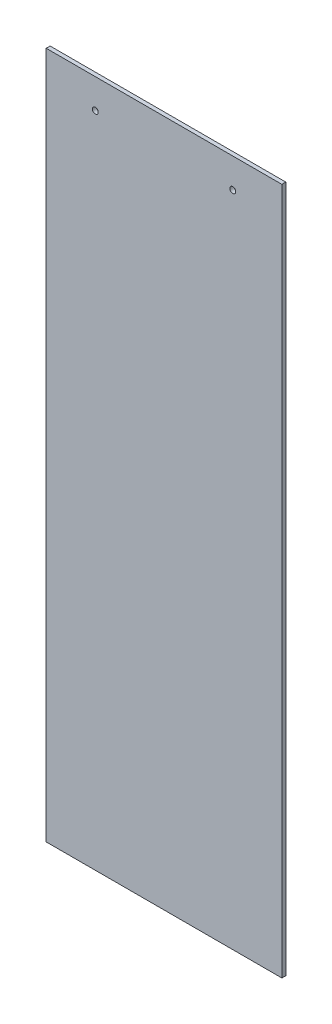
from build123d import *

# Parameters (mm, degrees)
SKETCH_1_W      = 120
SKETCH_1_H      = 350
SKETCH_1_R      = 1.5
EXTRUDE_1_DEPTH = 2


with BuildPart() as part:
    # 草图1 → 凸台-拉伸1 (new body)
    with BuildSketch(Plane.XY.offset(2)):
        Rectangle(SKETCH_1_W, SKETCH_1_H)
        with Locations((35, 160)):
            Circle(SKETCH_1_R, mode=Mode.SUBTRACT)
        with Locations((-35, 160)):
            Circle(SKETCH_1_R, mode=Mode.SUBTRACT)
    extrude(amount=-EXTRUDE_1_DEPTH)


solid = part.part
